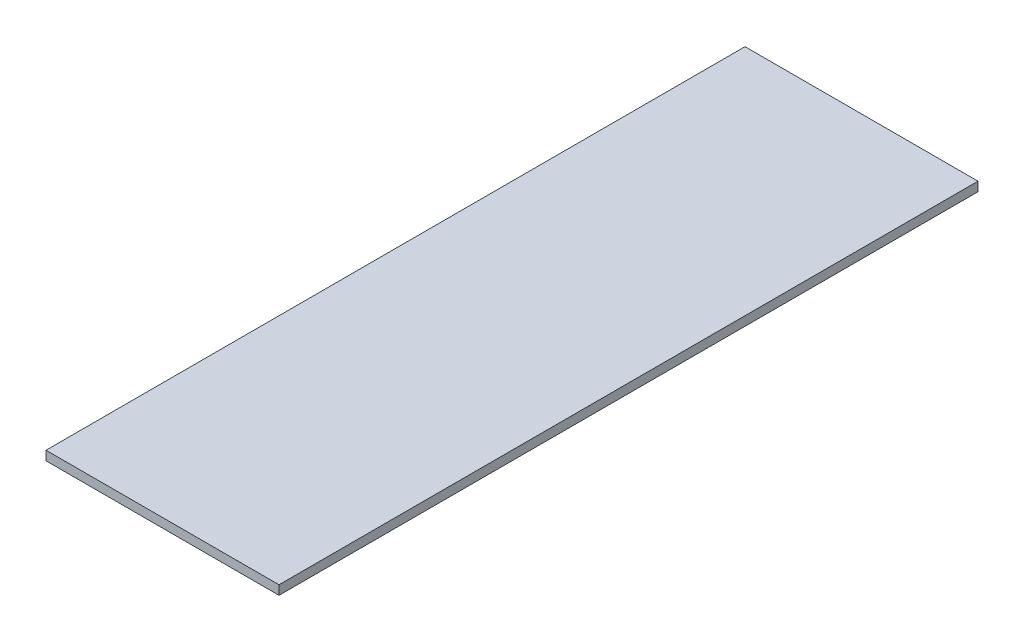
from build123d import *

# Parameters (mm, degrees)
SKETCH1_W           = 25.4
SKETCH1_H           = 76.2
BOSS_EXTRUDE1_DEPTH = 1


with BuildPart() as part:
    # Sketch1 → Boss-Extrude1 (new body)
    with BuildSketch(Plane(origin=(0, 0, 0), x_dir=(1, 0, 0), z_dir=(0, 1, 0))):
        with Locations((12.7, 38.1)):
            Rectangle(SKETCH1_W, SKETCH1_H)
    extrude(amount=BOSS_EXTRUDE1_DEPTH)


solid = part.part
